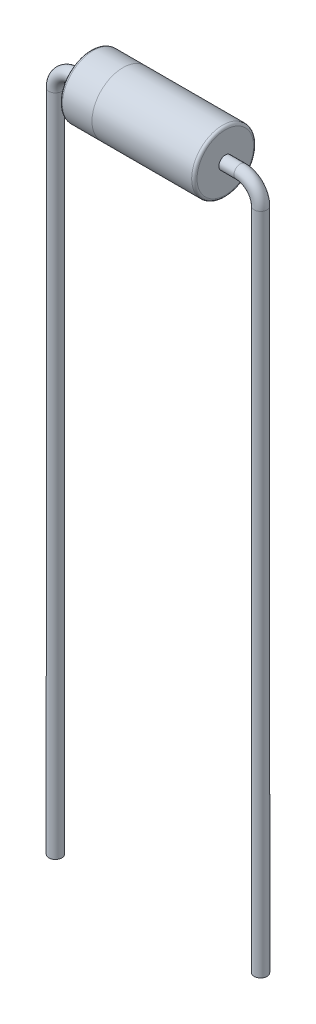
from build123d import *

# Parameters (mm, degrees)
SKETCH2_R = 0.24


with BuildPart() as part:
    # Sweep1: sweep along a path in Sketch1
    with BuildLine(Plane.XY) as sweep1_path:
        Line((-3.81, -25.4), (-3.81, -0.75))
        ThreePointArc((-3.81, -0.75), (-3.590330086, -0.219669914), (-3.06, 0))
        Line((-3.06, 0), (3.06, 0))
        ThreePointArc((3.06, 0), (3.590330086, -0.219669914), (3.81, -0.75))
        Line((3.81, -0.75), (3.81, -25.4))
    # Sketch2 → Sweep1 (sweep)
    with BuildSketch(Plane(origin=(-3.81, -25.4, 0), x_dir=(-1, 0, 0), z_dir=(0, -1, 0))):
        Circle(SKETCH2_R)
    sweep(path=sweep1_path.line)


with BuildPart() as body_2:
    # Sketch3 → Revolve1 (revolve)
    with BuildSketch(Plane.XY, mode=Mode.PRIVATE) as revolve1_sk:
        with BuildLine():
            Line((-1.3, 1.15), (2.4, 1.15))
            ThreePointArc((2.4, 1.15), (2.470710678, 1.120710678), (2.5, 1.05))
            Line((2.5, 1.05), (2.5, 0))
            Line((2.5, 0), (-1.3, 0))
            Line((-1.3, 0), (-1.3, 1.15))
        make_face()
    revolve(revolve1_sk.sketch.rotate(Axis((-1.3, 0, 0), (1, 0, 0)), 90), axis=Axis((-1.3, 0, 0), (1, 0, 0)))


with BuildPart() as body_3:
    # Sketch4 → Revolve2 (revolve)
    with BuildSketch(Plane.XY, mode=Mode.PRIVATE) as revolve2_sk:
        with BuildLine():
            Line((-2.5, 1.05), (-2.5, 0))
            Line((-2.5, 0), (-1.3, 0))
            Line((-1.3, 0), (-1.3, 1.15))
            Line((-1.3, 1.15), (-2.4, 1.15))
            ThreePointArc((-2.4, 1.15), (-2.470710678, 1.120710678), (-2.5, 1.05))
        make_face()
    revolve(revolve2_sk.sketch.rotate(Axis((-2.5, 0, 0), (1, 0, 0)), 90), axis=Axis((-2.5, 0, 0), (1, 0, 0)))


solid = Compound([part.part, body_2.part, body_3.part])
